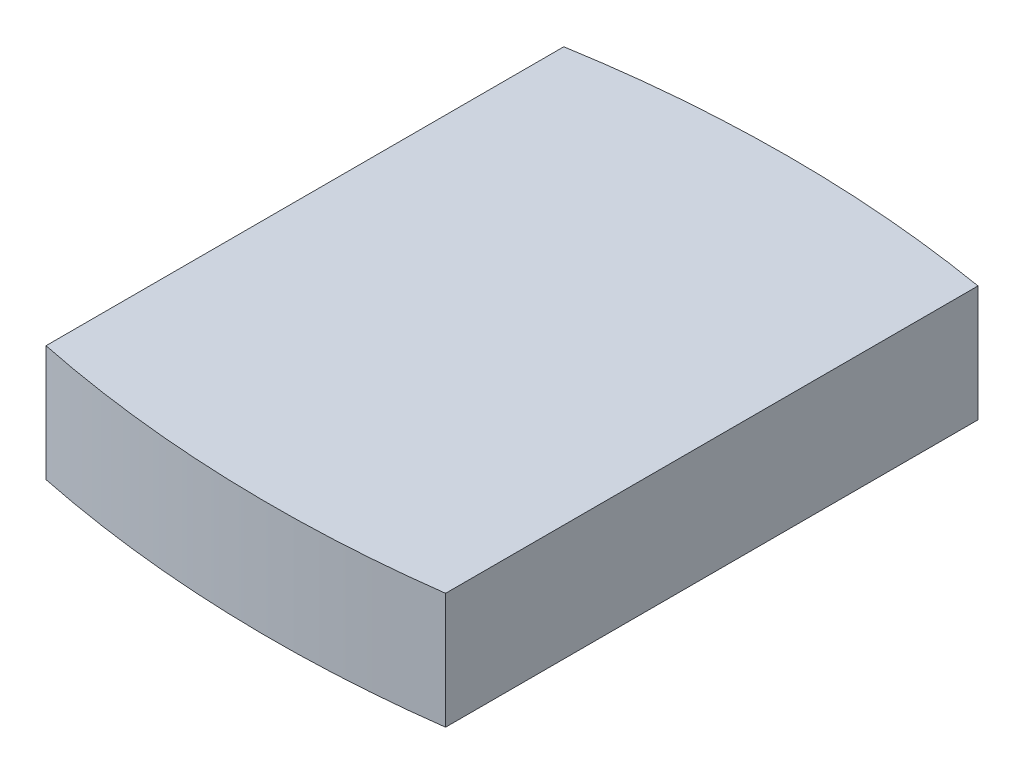
from build123d import *

# Parameters (mm, degrees)
EXTRUDE_1_DEPTH = 5.6


with BuildPart() as part:
    # Эскиз1 → Бобышка-Вытянуть1 (new body)
    with BuildSketch(Plane(origin=(0, 0, 0), x_dir=(1, 0, 0), z_dir=(0, 1, 0))):
        with BuildLine():
            Line((0, 0), (0, 25))
            ThreePointArc((0, 25), (10, 25.839202169), (20, 25))
            Line((20, 25), (20, -0.706999977))
            ThreePointArc((20, -0.706999977), (9.970315411, -1.19323378), (0, 0))
        make_face()
    extrude(amount=EXTRUDE_1_DEPTH)


solid = part.part
